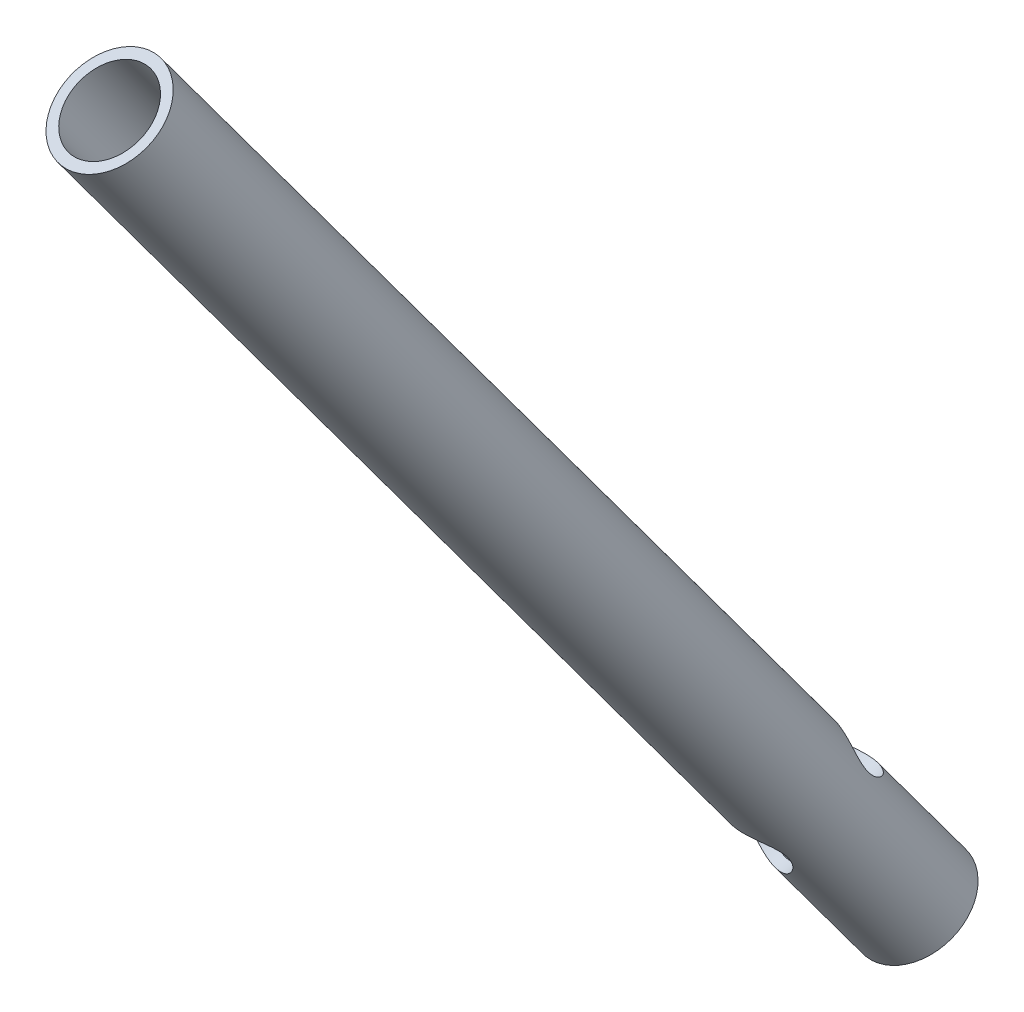
from build123d import *

# Parameters (mm, degrees)
SKETCH1_R                = 5
SKETCH1_R_2              = 4
BOSS_EXTRUDE1_DEPTH      = 80
BOSS_EXTRUDE1_DEPTH_BACK = 30
SKETCH2_R                = 3
CUT_EXTRUDE1_DEPTH       = 58.904930039
CUT_EXTRUDE1_DEPTH_BACK  = 58.904930039


with BuildPart() as part:
    # Sketch1 → Boss-Extrude1 (new body, two sides)
    with BuildSketch(Plane(origin=(-18.263591419, 106.35230846, 73.959767463), x_dir=(0.989737493, 0.132142803, 0.054387259), z_dir=(-0.139606326, 0.812953742, 0.565346165))) as boss_extrude1_sk:
        with Locations((75.664084078, -74.988676697)):
            Circle(SKETCH1_R)
        with Locations((75.664084078, -74.988676697)):
            Circle(SKETCH1_R_2, mode=Mode.SUBTRACT)
    extrude(amount=BOSS_EXTRUDE1_DEPTH)
    extrude(boss_extrude1_sk.sketch, amount=-BOSS_EXTRUDE1_DEPTH_BACK)

    # Sketch2 → Cut-Extrude1 (cut, two sides)
    with BuildSketch(Plane(origin=(167.461192563, -27.829766449, 89.299122305), x_dir=(0.974445609, 0.011329449, 0.22433769), z_dir=(-0.175971104, -0.582218049, 0.793760867))) as cut_extrude1_sk:
        with Locations((-93.296905198, 111.340129179)):
            Circle(SKETCH2_R)
    extrude(amount=CUT_EXTRUDE1_DEPTH, mode=Mode.SUBTRACT)
    extrude(cut_extrude1_sk.sketch, amount=-CUT_EXTRUDE1_DEPTH_BACK, mode=Mode.SUBTRACT)


solid = part.part
